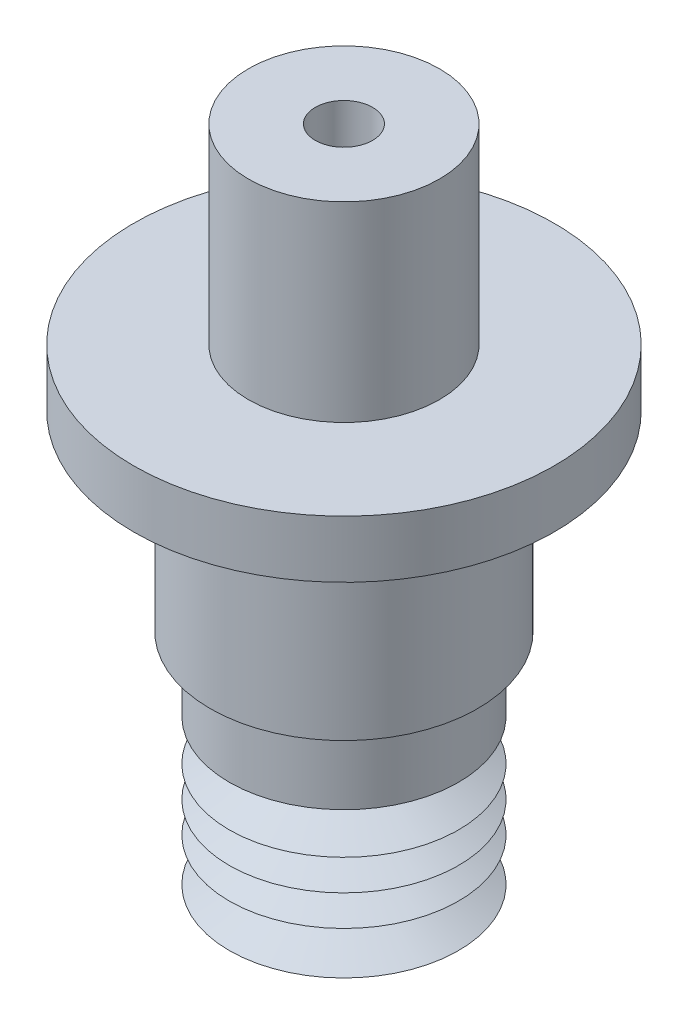
from build123d import *

# Parameters (mm, degrees)
SKETCH_2_R      = 7
EXTRUDE_1_DEPTH = 10
SKETCH_3_R      = 11
EXTRUDE_2_DEPTH = 3
SKETCH_4_R      = 5
SKETCH_4_R_2    = 1.5
EXTRUDE_3_DEPTH = 10


with BuildPart() as part:
    # 草图1 → 旋转1 (revolve)
    with BuildSketch(Plane(origin=(0, 0, 0), x_dir=(-1, 0, 0), z_dir=(0, 0, -1))):
        Polygon((-6, -4), (-3.705599294, -4), (-2.060062716, -3.203134621), (-3.998627726, -1.898006037), (-1.452745067, -0.665140249), (-3.391310077, 0.008460706), (-1.452745067, 0.947227648), (-3.391310077, 1.620828604), (-2.001444472, 2.293883094), (-5, 4.178313324), (-5, 6.465133326), (-2, 6.465133326), (-2, 7.465133326), (-6, 7.465133326), (-6, 3.625681691), (-4.06143499, 2.407398263), (-6, 1.468631321), (-4.06143499, 0.795030366), (-6, -0.143736577), (-4.06143499, -0.817337532), (-6, -1.756104474), (-4.06143499, -3.061233058), align=None)
    revolve(axis=Axis((0, -4, 0), (0, 1, 0)))

    # 草图2 → 凸台-拉伸1 (add)
    with BuildSketch(Plane(origin=(0, 7.465133326, 0), x_dir=(1, 0, 0), z_dir=(0, 1, 0))):
        Circle(SKETCH_2_R)
    extrude(amount=EXTRUDE_1_DEPTH)

    # 草图3 → 凸台-拉伸2 (add)
    with BuildSketch(Plane(origin=(0, 17.465133326, 0), x_dir=(1, 0, 0), z_dir=(0, 1, 0))):
        Circle(SKETCH_3_R)
    extrude(amount=EXTRUDE_2_DEPTH)

    # 草图4 → 凸台-拉伸3 (add)
    with BuildSketch(Plane(origin=(0, 20.465133326, 0), x_dir=(1, 0, 0), z_dir=(0, 1, 0))):
        Circle(SKETCH_4_R)
        Circle(SKETCH_4_R_2, mode=Mode.SUBTRACT)
    extrude(amount=EXTRUDE_3_DEPTH)


solid = part.part
